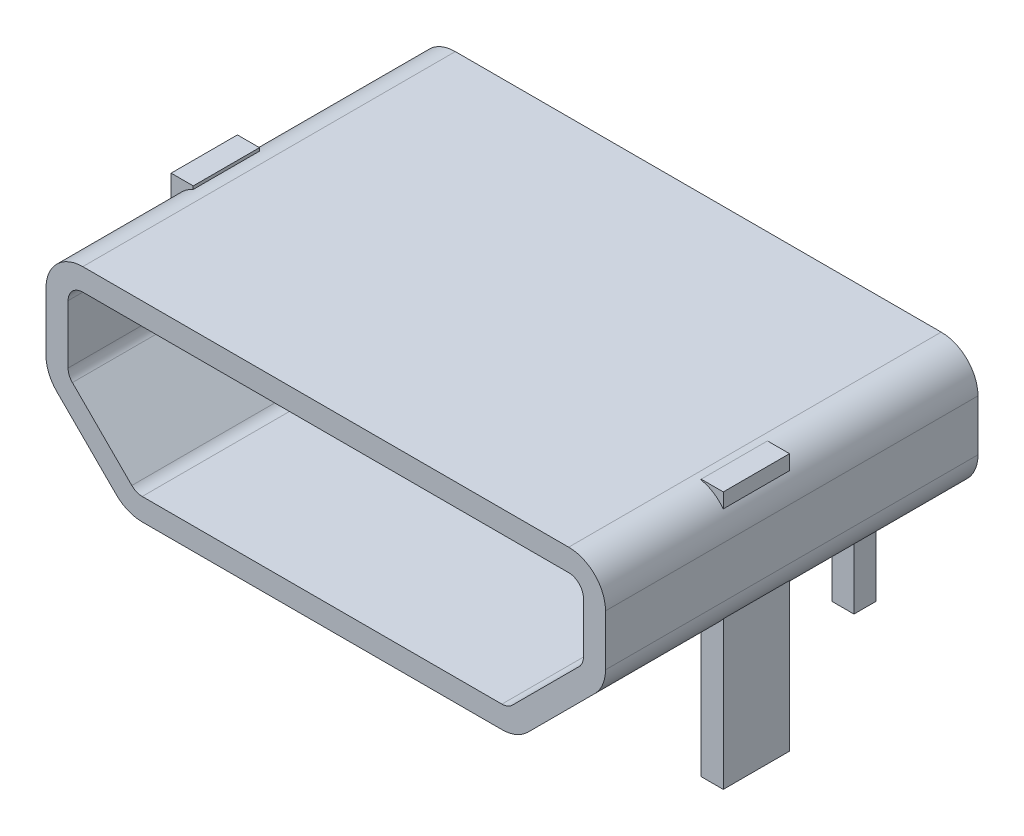
from build123d import *

# Parameters (mm, degrees)
EXTRUDE_1_DEPTH     = 5.06
CUT_EXTRUDE_1_REACH = 7.06
SKETCH_2_W          = 0.3
SKETCH_2_H          = 0.3
SKETCH_2_H_2        = 0.9
EXTRUDE_2_DEPTH     = 3.5


with BuildPart() as part:
    # 草图1 → 凸台-拉伸1 (new body)
    with BuildSketch(Plane.XY):
        with BuildLine():
            Line((-3.603553391, 0.953553391), (-2.796446609, 0.146446609))
            ThreePointArc((-2.796446609, 0.146446609), (-2.634234935, 0.038060234), (-2.442893219, 0))
            Line((-2.442893219, 0), (2.442893219, 0))
            ThreePointArc((2.442893219, 0), (2.634234935, 0.038060234), (2.796446609, 0.146446609))
            Line((2.796446609, 0.146446609), (3.703553391, 1.053553391))
            ThreePointArc((3.703553391, 1.053553391), (3.811939766, 1.215765065), (3.85, 1.407106781))
            Line((3.85, 1.407106781), (3.85, 2.1))
            ThreePointArc((3.85, 2.1), (3.703553391, 2.453553391), (3.35, 2.6))
            Line((3.35, 2.6), (-3.25, 2.6))
            ThreePointArc((-3.25, 2.6), (-3.603553391, 2.453553391), (-3.75, 2.1))
            Line((-3.75, 2.1), (-3.75, 1.307106781))
            ThreePointArc((-3.75, 1.307106781), (-3.711939766, 1.115765065), (-3.603553391, 0.953553391))
        make_face()
    extrude(amount=EXTRUDE_1_DEPTH)

    # 草图4 → 切除-拉伸1 (cut, up to next)
    with BuildSketch(Plane(origin=(0, 0, 0), x_dir=(-1, 0, 0), z_dir=(0, 0, -1)), mode=Mode.PRIVATE) as cut_extrude_1_sk1:
        with BuildLine():
            Line((-2.442893219, 0.3), (2.442893219, 0.3))
            ThreePointArc((2.442893219, 0.3), (2.519429905, 0.315224093), (2.584314575, 0.358578644))
            Line((2.584314575, 0.358578644), (3.391421356, 1.165685425))
            ThreePointArc((3.391421356, 1.165685425), (3.434775907, 1.230570095), (3.45, 1.307106781))
            Line((3.45, 1.307106781), (3.45, 2.1))
            ThreePointArc((3.45, 2.1), (3.391421356, 2.241421356), (3.25, 2.3))
            Line((3.25, 2.3), (-3.35, 2.3))
            ThreePointArc((-3.35, 2.3), (-3.491421356, 2.241421356), (-3.55, 2.1))
            Line((-3.55, 2.1), (-3.55, 1.407106781))
            ThreePointArc((-3.55, 1.407106781), (-3.534775907, 1.330570095), (-3.491421356, 1.265685425))
            Line((-3.491421356, 1.265685425), (-2.584314575, 0.358578644))
            ThreePointArc((-2.584314575, 0.358578644), (-2.519429905, 0.315224093), (-2.442893219, 0.3))
        make_face()
    cut_extrude_1_tool1 = extrude(cut_extrude_1_sk1.sketch, amount=-CUT_EXTRUDE_1_REACH, mode=Mode.PRIVATE) & part.part
    add(cut_extrude_1_tool1.solids().sort_by_distance((0.027478, 1.348077, 0))[0], mode=Mode.SUBTRACT)

    # 草图2 → 凸台-拉伸2 (add)
    with BuildSketch(Plane(origin=(0, 2.6, 0), x_dir=(1, 0, 0), z_dir=(0, 1, 0))):
        with Locations((-2.425, -0.26)):
            Rectangle(SKETCH_2_W, SKETCH_2_H)
        with Locations((-3.6, -2.91)):
            Rectangle(SKETCH_2_W, SKETCH_2_H_2)
        with Locations((3.6, -2.91)):
            Rectangle(SKETCH_2_W, SKETCH_2_H_2)
        with Locations((2.425, -0.26)):
            Rectangle(SKETCH_2_W, SKETCH_2_H)
    extrude(amount=-EXTRUDE_2_DEPTH)


solid = part.part
